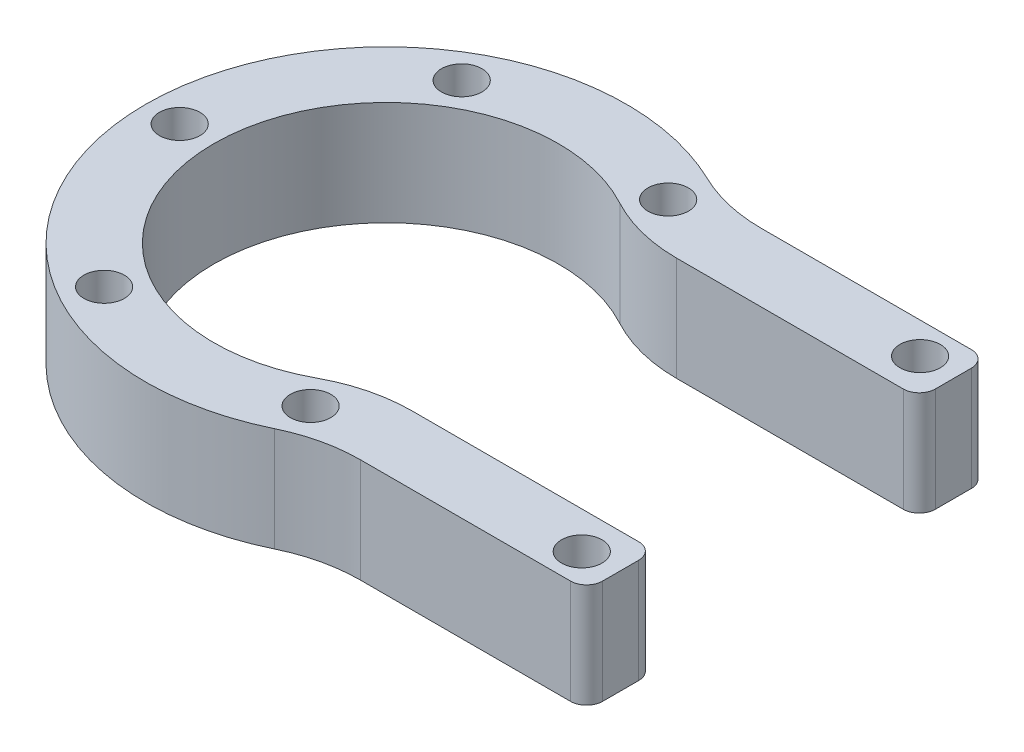
from build123d import *

# Parameters (mm, degrees)
EXTRUDE_1_DEPTH     = 13
SKETCH_2_R          = 2.525
CUT_EXTRUDE_1_DEPTH = 14
CUT_EXTRUDE_2_DEPTH = 14
SKETCH_4_R          = 2.525
CUT_EXTRUDE_3_DEPTH = 14
SKETCH_5_W          = 8
SKETCH_5_H          = 50
CUT_EXTRUDE_4_DEPTH = 14
SKETCH_6_R          = 1.525
CUT_EXTRUDE_5_DEPTH = 14
SKETCH_7_W          = 12
SKETCH_7_H          = 55
CUT_EXTRUDE_6_DEPTH = 14
FILLET_1_R          = 20
FILLET_2_R          = 20
FILLET_3_R          = 2


with BuildPart() as part:
    # 草图1 → 凸台-拉伸1 (new body)
    with BuildSketch(Plane(origin=(0, 0, 0), x_dir=(1, 0, 0), z_dir=(0, 1, 0))):
        with BuildLine():
            ThreePointArc((16.583123952, 25), (-30, 0), (16.583123952, -25))
            Line((16.583123952, -25), (16.583123952, 25))
        make_face()
        with BuildLine():
            Line((16.583123952, 25), (16.583123952, -25))
            ThreePointArc((16.583123952, -25), (26.433820369, -14.186371655), (30, 0))
            ThreePointArc((30, 0), (26.433820369, 14.186371655), (16.583123952, 25))
        make_face()
        with BuildLine():
            ThreePointArc((30, 0), (26.433820369, -14.186371655), (16.583123952, -25))
            Line((16.583123952, -25), (70, -25))
            Line((70, -25), (70, 25))
            Line((70, 25), (16.583123952, 25))
            ThreePointArc((16.583123952, 25), (26.433820369, 14.186371655), (30, 0))
        make_face()
    extrude(amount=EXTRUDE_1_DEPTH)

    # 草图2 → 切除-拉伸1 (cut, through all)
    with BuildSketch(Plane(origin=(0, 13, 0), x_dir=(1, 0, 0), z_dir=(0, 1, 0))):
        with Locations((-25.75, 0)):
            Circle(SKETCH_2_R)
        with Locations((-12.875, 22.300154147)):
            Circle(SKETCH_2_R)
        with Locations((12.875, 22.300154147)):
            Circle(SKETCH_2_R)
        with Locations((25.75, 0)):
            Circle(SKETCH_2_R)
        with Locations((12.875, -22.300154147)):
            Circle(SKETCH_2_R)
        with Locations((-12.875, -22.300154147)):
            Circle(SKETCH_2_R)
    extrude(amount=-CUT_EXTRUDE_1_DEPTH, mode=Mode.SUBTRACT)

    # 草图3 → 切除-拉伸2 (cut, through all)
    with BuildSketch(Plane(origin=(0, 13, 0), x_dir=(1, 0, 0), z_dir=(0, 1, 0))):
        with BuildLine():
            Line((13.784048752, -16.5), (52, -16.5))
            Line((52, -16.5), (52, 16.5))
            Line((52, 16.5), (13.784048752, 16.5))
            ThreePointArc((13.784048752, 16.5), (-21.5, 0), (13.784048752, -16.5))
        make_face()
    extrude(amount=-CUT_EXTRUDE_2_DEPTH, mode=Mode.SUBTRACT)

    # 草图4 → 切除-拉伸3 (cut, through all)
    with BuildSketch(Plane(origin=(0, 13, 0), x_dir=(1, 0, 0), z_dir=(0, 1, 0))):
        with Locations((45.5, 21.1)):
            Circle(SKETCH_4_R)
        with Locations((45.5, -21.1)):
            Circle(SKETCH_4_R)
    extrude(amount=-CUT_EXTRUDE_3_DEPTH, mode=Mode.SUBTRACT)

    # 草图5 → 切除-拉伸4 (cut, through all)
    with BuildSketch(Plane(origin=(0, 13, 0), x_dir=(1, 0, 0), z_dir=(0, 1, 0))):
        with Locations((66, 0)):
            Rectangle(SKETCH_5_W, SKETCH_5_H)
    extrude(amount=-CUT_EXTRUDE_4_DEPTH, mode=Mode.SUBTRACT)

    # 草图6 → 切除-拉伸5 (cut, through all)
    with BuildSketch(Plane(origin=(0, 13, 0), x_dir=(1, 0, 0), z_dir=(0, 1, 0))):
        with Locations((56, 0)):
            Circle(SKETCH_6_R)
        with Locations((56, 15)):
            Circle(SKETCH_6_R)
        with Locations((56, -15)):
            Circle(SKETCH_6_R)
    extrude(amount=-CUT_EXTRUDE_5_DEPTH, mode=Mode.SUBTRACT)

    # 草图7 → 切除-拉伸6 (cut, through all)
    with BuildSketch(Plane(origin=(0, 13, 0), x_dir=(1, 0, 0), z_dir=(0, 1, 0))):
        with Locations((56, -2.5)):
            Rectangle(SKETCH_7_W, SKETCH_7_H)
    extrude(amount=-CUT_EXTRUDE_6_DEPTH, mode=Mode.SUBTRACT)

    # 圆角1
    fillet_1_edges = [part.edges().sort_by_distance(p)[0] for p in [
        (13.784048752, 6.5, -16.5),
        (13.784048752, 6.5, 16.5),
    ]]
    fillet(fillet_1_edges, radius=FILLET_1_R)

    # 圆角2
    fillet_2_edges = [part.edges().sort_by_distance(p)[0] for p in [
        (16.583123952, 6.5, -25),
        (16.583123952, 6.5, 25),
    ]]
    fillet(fillet_2_edges, radius=FILLET_2_R)

    # 圆角3
    fillet_3_edges = [part.edges().sort_by_distance(p)[0] for p in [
        (50, 6.5, 16.5),
        (50, 6.5, 25),
        (50, 6.5, -16.5),
        (50, 6.5, -25),
    ]]
    fillet(fillet_3_edges, radius=FILLET_3_R)


solid = part.part
